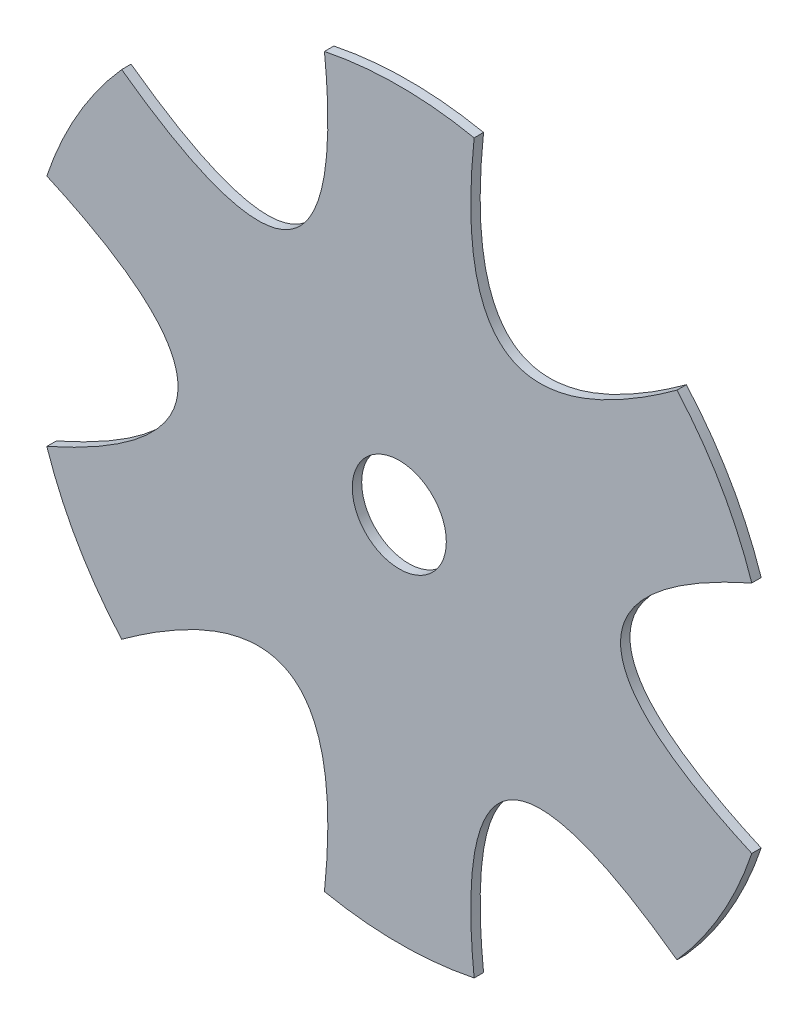
from build123d import *

# Parameters (mm, degrees)
SKETCH1_R           = 125.4125
BOSS_EXTRUDE1_DEPTH = 3.175
CUT_EXTRUDE1_DEPTH  = 4.175
CIRPATTERN1_COUNT   = 6
SKETCH3_R           = 15.875
CUT_EXTRUDE2_DEPTH  = 50.8


with BuildPart() as part:
    # Sketch1 → Boss-Extrude1 (new body)
    with BuildSketch(Plane.XY):
        Circle(SKETCH1_R)
    extrude(amount=BOSS_EXTRUDE1_DEPTH)

    # Sketch2 → Cut-Extrude1 (cut, through all)
    with BuildSketch(Plane.XY.offset(3.175)):
        with BuildLine():
            ThreePointArc((93.748147638, 83.304141377), (62.70625, 108.610410952), (25.269428854, 122.840348101))
            add(Edge.make_bspline(
                [(93.748147638, 83.304141377), (15.206576878, 26.338563761), (25.269428854, 122.840348101)],
                knots=[0, 0, 0, 1, 1, 1], degree=2))
        make_face()
    cut_extrude1 = extrude(amount=-CUT_EXTRUDE1_DEPTH, mode=Mode.SUBTRACT)

    # CirPattern1: Cut-Extrude1 ×6 about axis
    cirpattern1_axis = Axis((0, 0, 3.175), (0, 0, -1))
    for i in range(1, CIRPATTERN1_COUNT):
        add(cut_extrude1.rotate(cirpattern1_axis, i * 360 / CIRPATTERN1_COUNT), mode=Mode.SUBTRACT)

    # Sketch3 → Cut-Extrude2 (cut)
    with BuildSketch(Plane(origin=(0, 0, 0), x_dir=(-1, 0, 0), z_dir=(0, 0, -1))):
        Circle(SKETCH3_R)
    extrude(amount=-CUT_EXTRUDE2_DEPTH, mode=Mode.SUBTRACT)


solid = part.part
